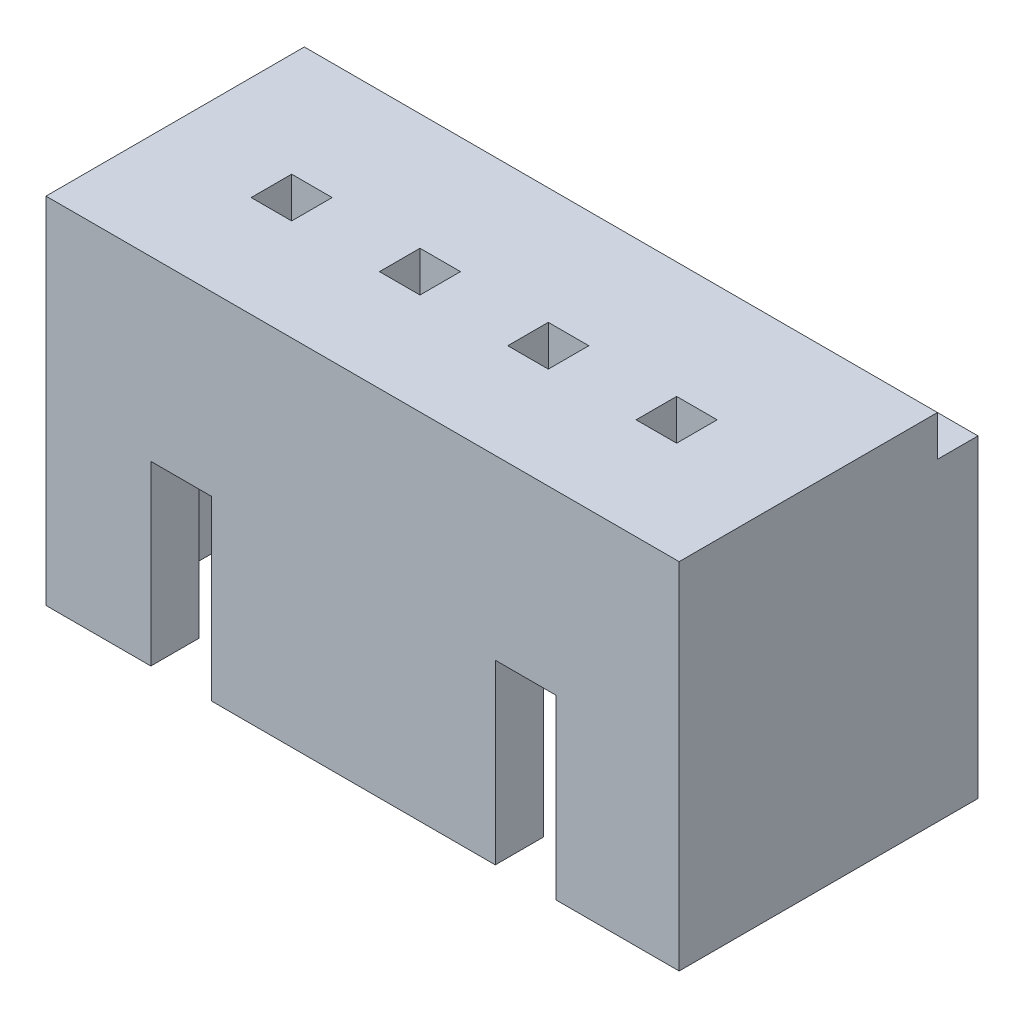
from build123d import *

# Parameters (mm, degrees)
SKETCH1_W           = 12.5
SKETCH1_H           = 5.9
BOSS_EXTRUDE1_DEPTH = 7
SKETCH3_W           = 11
SKETCH3_H           = 4
CUT_EXTRUDE1_DEPTH  = 5
SKETCH4_W           = 1.2
SKETCH4_H           = 3.5
CUT_EXTRUDE2_DEPTH  = 4
SKETCH5_W           = 12.5
SKETCH5_H           = 0.8
CUT_EXTRUDE3_DEPTH  = 0.8
SKETCH6_W           = 0.8
SKETCH6_H           = 0.8
CUT_EXTRUDE4_DEPTH  = 10
SKETCH7_W           = 11
SKETCH7_H           = 1
CUT_EXTRUDE5_DEPTH  = 0.3


with BuildPart() as part:
    # Sketch1 → Boss-Extrude1 (new body)
    with BuildSketch(Plane(origin=(0, 0, 0), x_dir=(1, 0, 0), z_dir=(0, 1, 0))):
        Rectangle(SKETCH1_W, SKETCH1_H)
    extrude(amount=BOSS_EXTRUDE1_DEPTH)

    # Sketch3 → Cut-Extrude1 (cut)
    with BuildSketch(Plane.XZ):
        Rectangle(SKETCH3_W, SKETCH3_H)
    extrude(amount=-CUT_EXTRUDE1_DEPTH, mode=Mode.SUBTRACT)

    # Sketch4 → Cut-Extrude2 (cut)
    with BuildSketch(Plane.XY.offset(2.95)):
        with Locations((-3.58, 1.75)):
            Rectangle(SKETCH4_W, SKETCH4_H)
        with Locations((3.22, 1.75)):
            Rectangle(SKETCH4_W, SKETCH4_H)
    extrude(amount=-CUT_EXTRUDE2_DEPTH, mode=Mode.SUBTRACT)

    # Sketch5 → Cut-Extrude3 (cut)
    with BuildSketch(Plane(origin=(0, 7, 0), x_dir=(1, 0, 0), z_dir=(0, 1, 0))):
        with Locations((0, 2.55)):
            Rectangle(SKETCH5_W, SKETCH5_H)
    extrude(amount=-CUT_EXTRUDE3_DEPTH, mode=Mode.SUBTRACT)

    # Sketch6 → Cut-Extrude4 (cut)
    with BuildSketch(Plane(origin=(0, 7, 0), x_dir=(1, 0, 0), z_dir=(0, 1, 0))):
        with Locations((3.8, -0.55)):
            Rectangle(SKETCH6_W, SKETCH6_H)
        with Locations((1.266666667, -0.55)):
            Rectangle(SKETCH6_W, SKETCH6_H)
        with Locations((-1.266666667, -0.55)):
            Rectangle(SKETCH6_W, SKETCH6_H)
        with Locations((-3.8, -0.55)):
            Rectangle(SKETCH6_W, SKETCH6_H)
    extrude(amount=-CUT_EXTRUDE4_DEPTH, mode=Mode.SUBTRACT)

    # Sketch7 → Cut-Extrude5 (cut)
    with BuildSketch(Plane.XZ.offset(-5)):
        with Locations((0, -1.5)):
            Rectangle(SKETCH7_W, SKETCH7_H)
    extrude(amount=-CUT_EXTRUDE5_DEPTH, mode=Mode.SUBTRACT)


solid = part.part
